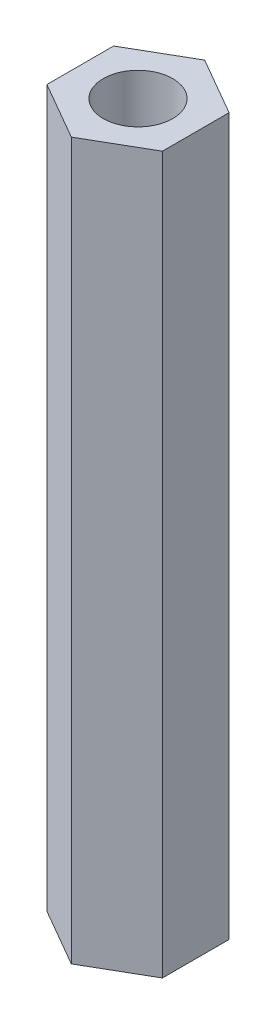
from build123d import *

# Parameters (mm, degrees)
BOSS_EXTRUDE1_DEPTH = 31
SKETCH2_R           = 1.5025
CUT_EXTRUDE1_DEPTH  = 6.005
SKETCH3_R           = 1.5025
CUT_EXTRUDE2_DEPTH  = 3.005


with BuildPart() as part:
    # Sketch1 → Boss-Extrude1 (new body)
    with BuildSketch(Plane(origin=(0, 0, 0), x_dir=(1, 0, 0), z_dir=(0, 1, 0))):
        Polygon((2.5, 1.443375673), (0, 2.886751346), (-2.5, 1.443375673), (-2.5, -1.443375673), (0, -2.886751346), (2.5, -1.443375673), align=None)
    extrude(amount=BOSS_EXTRUDE1_DEPTH)

    # Sketch2 → Cut-Extrude1 (cut)
    with BuildSketch(Plane(origin=(0, 0, 0), x_dir=(1, 0, 0), z_dir=(0, 1, 0))):
        Circle(SKETCH2_R)
    extrude(amount=CUT_EXTRUDE1_DEPTH, mode=Mode.SUBTRACT)

    # Sketch3 → Cut-Extrude2 (cut)
    with BuildSketch(Plane(origin=(0, 31, 0), x_dir=(1, 0, 0), z_dir=(0, 1, 0))):
        Circle(SKETCH3_R)
    extrude(amount=-CUT_EXTRUDE2_DEPTH, mode=Mode.SUBTRACT)


solid = part.part
